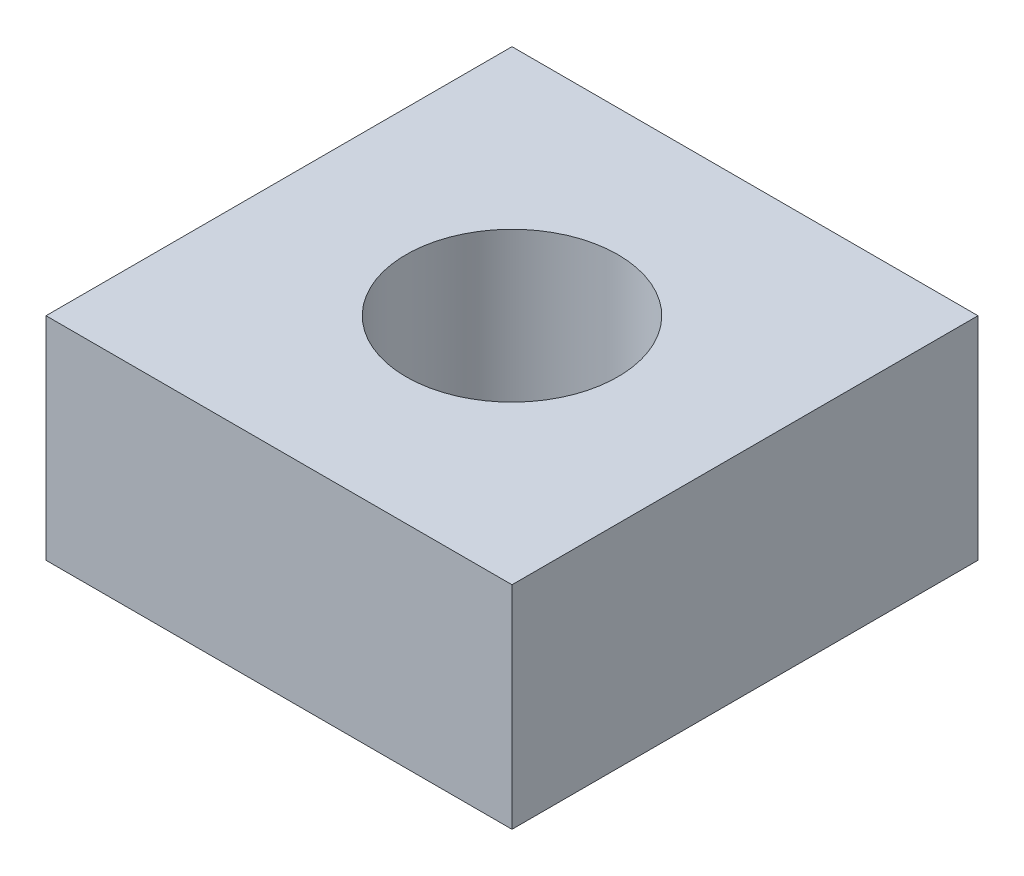
from build123d import *

# Parameters (mm, degrees)
SKETCH1_W           = 5.5
SKETCH1_H           = 5.5
BOSS_EXTRUDE1_DEPTH = 1.25
SKETCH4_W           = 1.25
SKETCH4_H           = 2.501


with BuildPart() as part:
    # Sketch1 → Boss-Extrude1 (new body, symmetric)
    with BuildSketch(Plane(origin=(0, 0, 0), x_dir=(1, 0, 0), z_dir=(0, 1, 0))):
        Rectangle(SKETCH1_W, SKETCH1_H)
    extrude(amount=BOSS_EXTRUDE1_DEPTH, both=True)

    # Sketch4 → Tap Drill for M3x0.5 Tap1 (revolve, cut)
    with BuildSketch(Plane(origin=(0, 1.25, 0), x_dir=(0, 0, 1), z_dir=(1, 0, 0))):
        with Locations((0.625, 1.2505)):
            Rectangle(SKETCH4_W, SKETCH4_H)
    revolve(axis=Axis((0, 7.6, 0), (0, -1, 0)), mode=Mode.SUBTRACT)


solid = part.part
